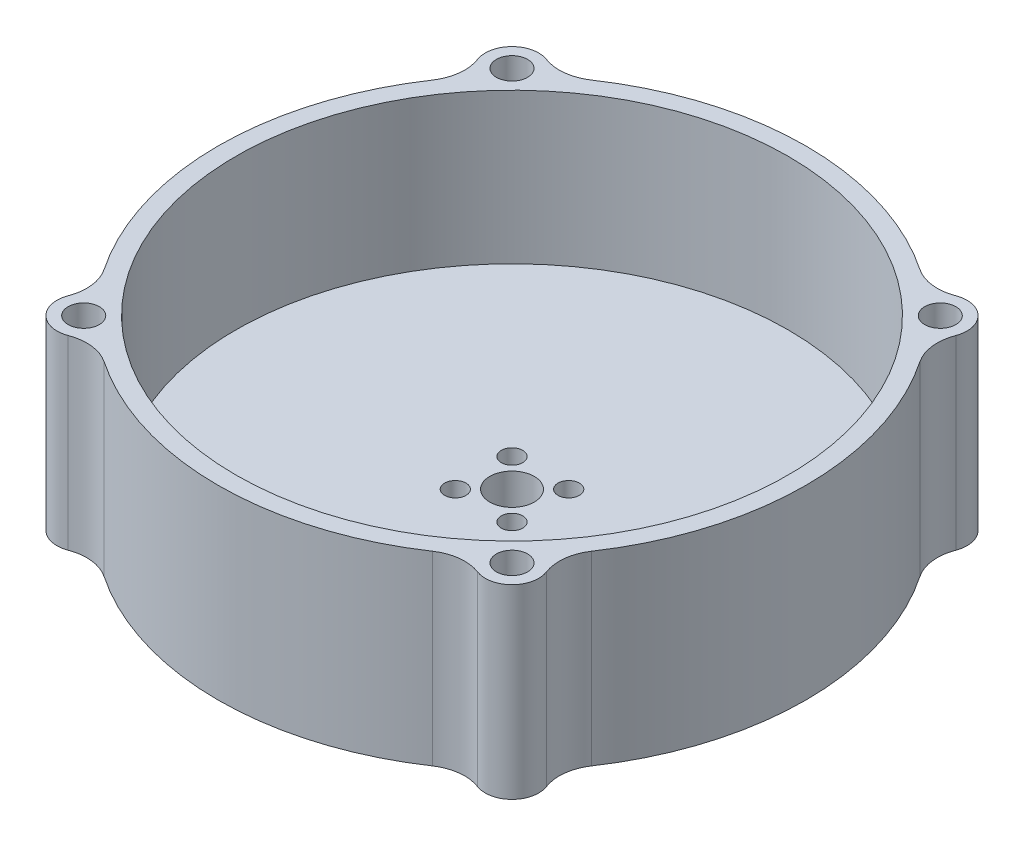
from build123d import *

# Parameters (mm, degrees)
SKETCH1_R                = 33
BOSS_EXTRUDE1_DEPTH      = 4
SKETCH2_R                = 33
SKETCH2_R_2              = 31
BOSS_EXTRUDE2_DEPTH      = 16.88
M2_CLEARANCE_HOLE1_D     = 2.4
SKETCH13_R               = 2.5
CUT_EXTRUDE3_DEPTH       = 5
CUT_EXTRUDE2_DEPTH       = 5
SKETCH15_R               = 3
BOSS_EXTRUDE3_DEPTH      = 20.88
FILLET1_R                = 5
CIRPATTERN1_COUNT        = 4
FILLET1_OF_CIRPATTERN1_R = 5
F_3_0_MM_DOWEL_HOLES1_D  = 3.5


with BuildPart() as part:
    # Sketch1 → Boss-Extrude1 (new body)
    with BuildSketch(Plane(origin=(0, 0, 0), x_dir=(1, 0, 0), z_dir=(0, 1, 0))):
        Circle(SKETCH1_R)
    extrude(amount=BOSS_EXTRUDE1_DEPTH)

    # Sketch2 → Boss-Extrude2 (add)
    with BuildSketch(Plane(origin=(0, 4, 0), x_dir=(1, 0, 0), z_dir=(0, 1, 0))):
        Circle(SKETCH2_R)
        Circle(SKETCH2_R_2, mode=Mode.SUBTRACT)
    extrude(amount=BOSS_EXTRUDE2_DEPTH)

    # M2 Clearance Hole1 (through all)
    with Locations(Plane(origin=(0, 0, 0), x_dir=(-1, 0, 0), z_dir=(0, -1, 0))):
        with Locations((3.181980515, 3.181980515), (3.181980515, -3.181980515), (-3.181980515, -3.181980515), (-3.181980515, 3.181980515)):
            Hole(M2_CLEARANCE_HOLE1_D / 2)

    # Sketch13 → Cut-Extrude3 (cut, through all)
    with BuildSketch(Plane(origin=(0, 4, 0), x_dir=(1, 0, 0), z_dir=(0, 1, 0))):
        Circle(SKETCH13_R)
    extrude(amount=-CUT_EXTRUDE3_DEPTH, mode=Mode.SUBTRACT)

    # Sketch10 → Cut-Extrude2 (cut, through all)
    with BuildSketch(Plane(origin=(0, 4, 0), x_dir=(1, 0, 0), z_dir=(0, 1, 0))):
        with BuildLine():
            Line((13.5, -4), (13.5, 4))
            ThreePointArc((13.5, 4), (15, 5.5), (16.5, 4))
            Line((16.5, 4), (16.5, -4))
            ThreePointArc((16.5, -4), (15, -5.5), (13.5, -4))
        make_face()
    extrude(amount=-CUT_EXTRUDE2_DEPTH, mode=Mode.SUBTRACT)

    # Sketch15 → Boss-Extrude3 (add, through all)
    with BuildSketch(Plane(origin=(0, 20.88, 0), x_dir=(1, 0, 0), z_dir=(0, 1, 0))):
        with Locations((24.04163056, 24.04163056)):
            Circle(SKETCH15_R)
    boss_extrude3 = extrude(amount=-BOSS_EXTRUDE3_DEPTH)

    # Fillet1
    fillet1_edges = [part.edges().sort_by_distance(p)[0] for p in [
        (25.219946573, 10.44, -21.282722919),
        (21.282722919, 10.44, -25.219946573),
    ]]
    fillet(fillet1_edges, radius=FILLET1_R)

    # CirPattern1: Boss-Extrude3 ×4 about axis
    cirpattern1_axis = Axis((0, 0, 0), (0, 1, 0))
    for i in range(1, CIRPATTERN1_COUNT):
        add(boss_extrude3.rotate(cirpattern1_axis, i * 360 / CIRPATTERN1_COUNT))

    # Fillet1 of CirPattern1
    fillet1_of_cirpattern1_edges = [part.edges().sort_by_distance(p)[0] for p in [
        (-21.282722919, 10.44, -25.219946573),
        (-25.219946573, 10.44, -21.282722919),
        (-25.219946573, 10.44, 21.282722919),
        (-21.282722919, 10.44, 25.219946573),
        (21.282722919, 10.44, 25.219946573),
        (25.219946573, 10.44, 21.282722919),
    ]]
    fillet(fillet1_of_cirpattern1_edges, radius=FILLET1_OF_CIRPATTERN1_R)

    # Ø3.0 mm Dowel Holes1 (through all)
    with Locations(Plane(origin=(0, 20.88, 0), x_dir=(1, 0, 0), z_dir=(0, 1, 0))):
        with Locations((24.04163056, -24.04163056), (-24.04163056, -24.04163056), (-24.04163056, 24.04163056), (24.04163056, 24.04163056)):
            Hole(F_3_0_MM_DOWEL_HOLES1_D / 2)


solid = part.part
